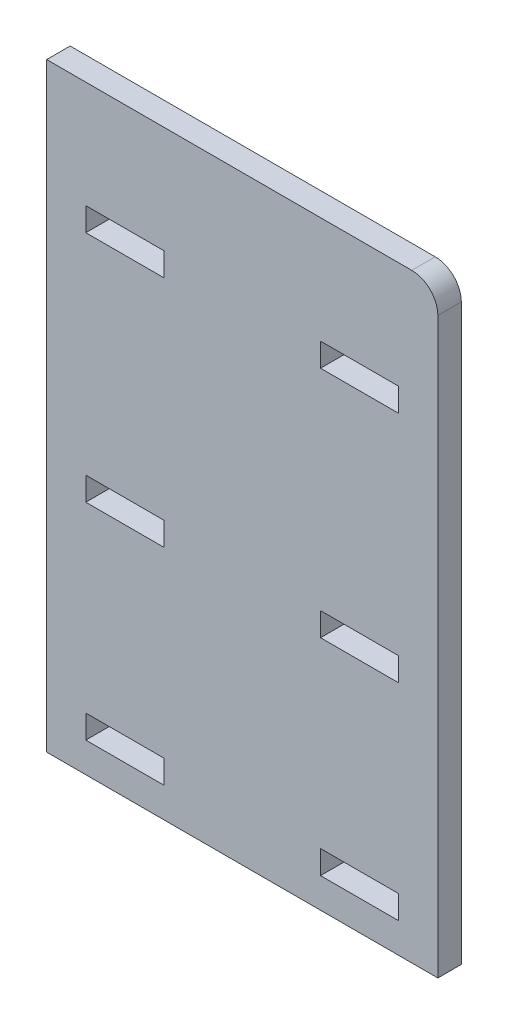
from build123d import *

# Parameters (mm, degrees)
SKETCH1_W           = 75
SKETCH1_H           = 115
SKETCH1_W_2         = 15
SKETCH1_H_2         = 4.5
BOSS_EXTRUDE1_DEPTH = 4.5
FILLET1_R           = 5


with BuildPart() as part:
    # Sketch1 → Boss-Extrude1 (new body)
    with BuildSketch(Plane.XY):
        Rectangle(SKETCH1_W, SKETCH1_H)
        with Locations((22.5, 34.75)):
            Rectangle(SKETCH1_W_2, SKETCH1_H_2, mode=Mode.SUBTRACT)
        with Locations((-22.5, 34.75)):
            Rectangle(SKETCH1_W_2, SKETCH1_H_2, mode=Mode.SUBTRACT)
        with Locations((22.5, -10)):
            Rectangle(SKETCH1_W_2, SKETCH1_H_2, mode=Mode.SUBTRACT)
        with Locations((-22.5, -10)):
            Rectangle(SKETCH1_W_2, SKETCH1_H_2, mode=Mode.SUBTRACT)
        with Locations((22.5, -49.5)):
            Rectangle(SKETCH1_W_2, SKETCH1_H_2, mode=Mode.SUBTRACT)
        with Locations((-22.5, -49.5)):
            Rectangle(SKETCH1_W_2, SKETCH1_H_2, mode=Mode.SUBTRACT)
    extrude(amount=BOSS_EXTRUDE1_DEPTH)

    # Fillet1
    fillet1_edges = [part.edges().sort_by_distance(p)[0] for p in [
        (37.5, 57.5, 2.25),
    ]]
    fillet(fillet1_edges, radius=FILLET1_R)


solid = part.part
